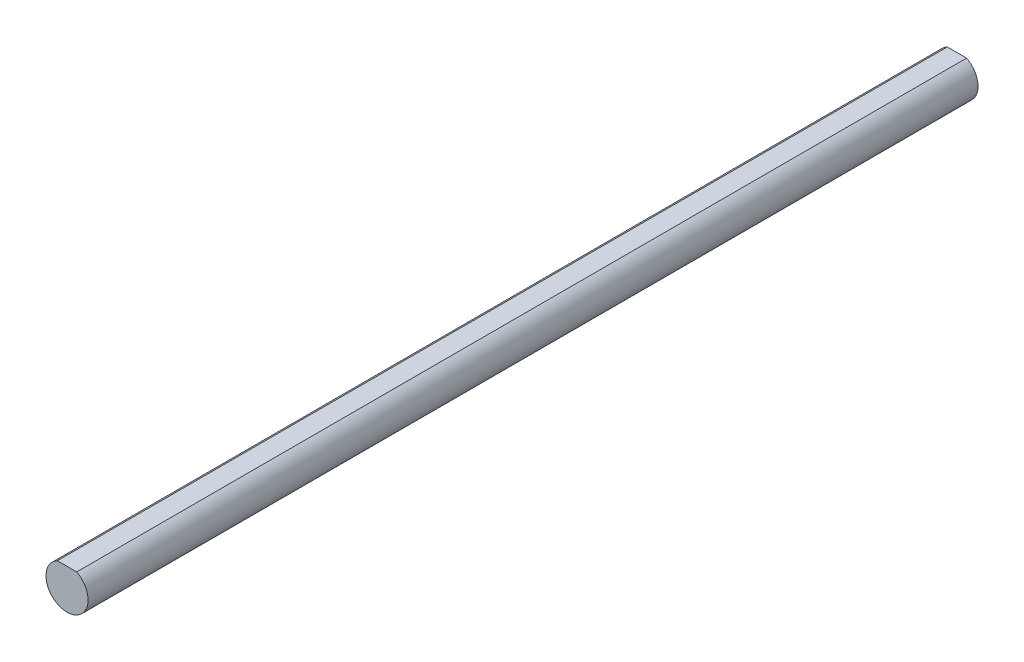
from build123d import *

# Parameters (mm, degrees)
BOSS_EXTRUDE1_DEPTH      = 50
BOSS_EXTRUDE1_DEPTH_BACK = 50


with BuildPart() as part:
    # Sketch1 → Boss-Extrude1 (new body, two sides)
    with BuildSketch(Plane.XY) as boss_extrude1_sk:
        with BuildLine():
            Line((1.087761463, 2.1), (-1.087761463, 2.1))
            ThreePointArc((-1.087761463, 2.1), (0, -2.365), (1.087761463, 2.1))
        make_face()
    extrude(amount=BOSS_EXTRUDE1_DEPTH)
    extrude(boss_extrude1_sk.sketch, amount=-BOSS_EXTRUDE1_DEPTH_BACK)


solid = part.part
